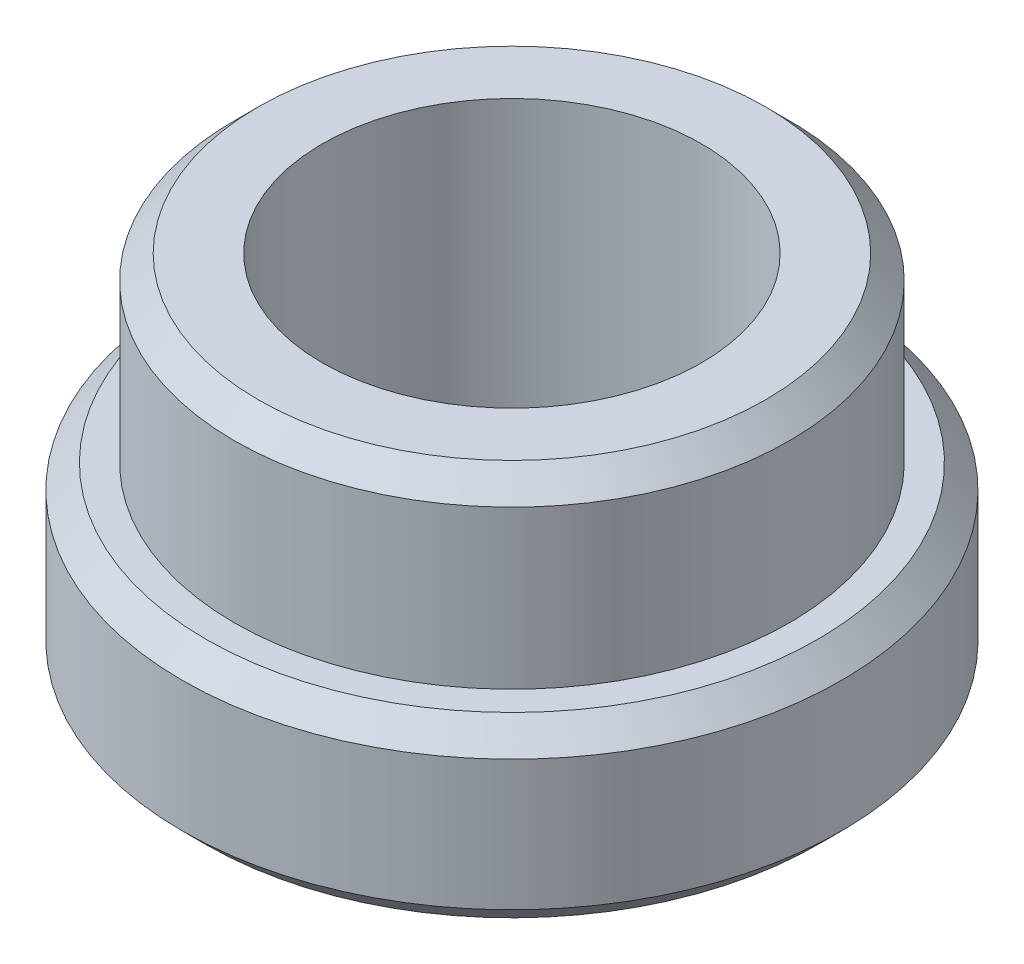
from build123d import *

# Parameters (mm, degrees)
SKETCH1_R           = 2.78
BOSS_EXTRUDE1_DEPTH = 1.5
CHAMFER1_SIZE       = 0.2
SKETCH2_R           = 2.34
BOSS_EXTRUDE2_DEPTH = 1.53
CHAMFER2_SIZE       = 0.2
SKETCH3_R           = 1.6
CUT_EXTRUDE1_DEPTH  = 4.03


with BuildPart() as part:
    # Sketch1 → Boss-Extrude1 (new body)
    with BuildSketch(Plane(origin=(0, 0, 0), x_dir=(1, 0, 0), z_dir=(0, 1, 0))):
        Circle(SKETCH1_R)
    extrude(amount=BOSS_EXTRUDE1_DEPTH)

    # Chamfer1
    chamfer1_edges = [part.edges().sort_by_distance(p)[0] for p in [
        (-2.78, 0, 0),
        (-2.78, 1.5, 0),
    ]]
    chamfer(chamfer1_edges, length=CHAMFER1_SIZE)

    # Sketch2 → Boss-Extrude2 (add)
    with BuildSketch(Plane(origin=(0, 1.5, 0), x_dir=(1, 0, 0), z_dir=(0, 1, 0))):
        Circle(SKETCH2_R)
    extrude(amount=BOSS_EXTRUDE2_DEPTH)

    # Chamfer2
    chamfer2_edges = [part.edges().sort_by_distance(p)[0] for p in [
        (-2.34, 3.03, 0),
    ]]
    chamfer(chamfer2_edges, length=CHAMFER2_SIZE)

    # Sketch3 → Cut-Extrude1 (cut, through all)
    with BuildSketch(Plane(origin=(0, 3.03, 0), x_dir=(1, 0, 0), z_dir=(0, 1, 0))):
        Circle(SKETCH3_R)
    extrude(amount=-CUT_EXTRUDE1_DEPTH, mode=Mode.SUBTRACT)


solid = part.part
